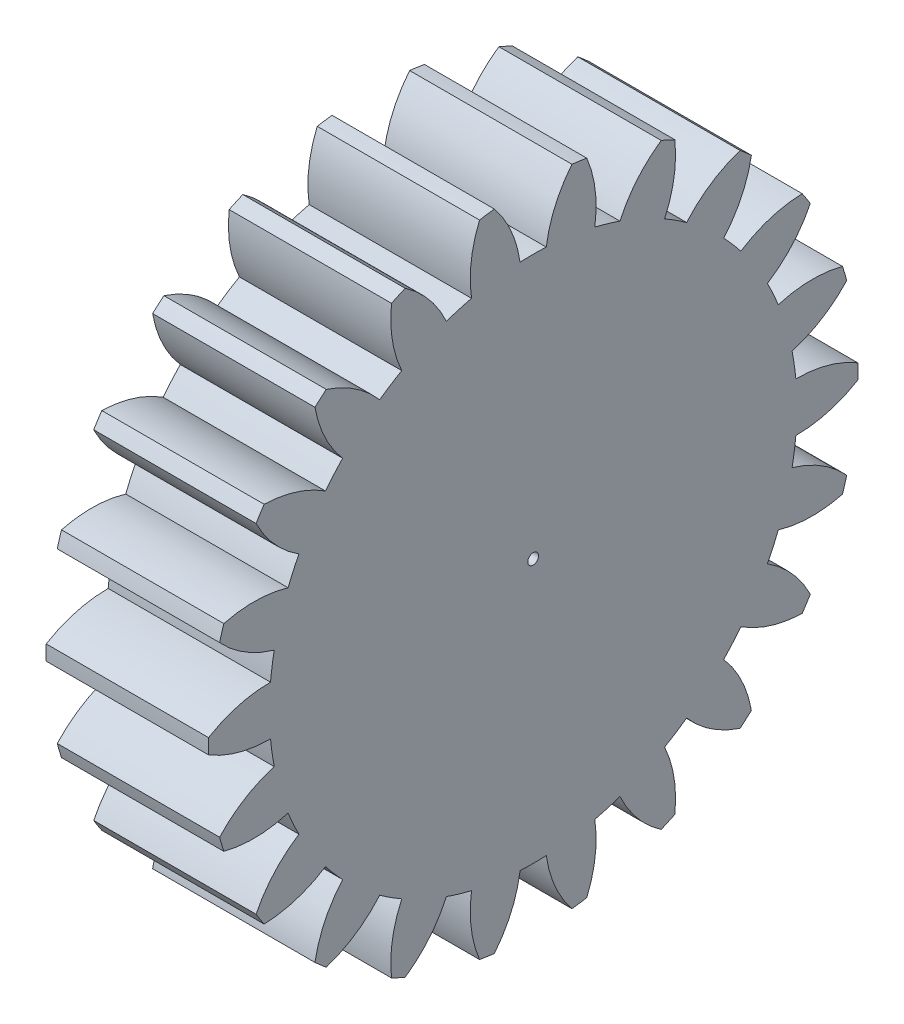
from build123d import *

# Parameters (mm, degrees)
BASPROSKE_W     = 12
BASPROSKE_H     = 24
TOOTHCUT_DEPTH  = 37
TEETHCUTS_COUNT = 22
TEETHCUTS_ANGLE = 343.636363636
BORSKE_R        = 0.4
BORE_DEPTH      = 50.0000508


with BuildPart() as part:
    # BasProSke → Base-Revolve (revolve)
    with BuildSketch(Plane(origin=(0, 0, 0), x_dir=(1, 0, 0), z_dir=(0, 1, 0)), mode=Mode.PRIVATE) as base_revolve_sk:
        with Locations((6, 12)):
            Rectangle(BASPROSKE_W, BASPROSKE_H)
    revolve(base_revolve_sk.sketch.rotate(Axis((-10, 0, 0), (1, 0, 0)), 180), axis=Axis((-10, 0, 0), (1, 0, 0)))

    # TooCutSke → ToothCut (cut, through all)
    with BuildSketch(Plane(origin=(0, 0, 0), x_dir=(0, 0, -1), z_dir=(1, 0, 0))):
        with BuildLine():
            ThreePointArc((0.968170358, 19.474949221), (0, 19.499), (-0.968170358, 19.474949221))
            ThreePointArc((-0.968170358, 19.474949221), (-1.624144469, 21.795843598), (-2.885568663, 23.851485041))
            ThreePointArc((-2.885568663, 23.851485041), (0, 24.0254), (2.885568663, 23.851485041))
            ThreePointArc((2.885568663, 23.851485041), (1.624144469, 21.795843598), (0.968170358, 19.474949221))
        make_face()
    toothcut = extrude(amount=TOOTHCUT_DEPTH, mode=Mode.SUBTRACT)

    # TeethCuts: ToothCut ×22 about axis
    teethcuts_axis = Axis((-10, 0, 0), (1, 0, 0))
    for i in range(1, TEETHCUTS_COUNT):
        add(toothcut.rotate(teethcuts_axis, i * TEETHCUTS_ANGLE / (TEETHCUTS_COUNT - 1)), mode=Mode.SUBTRACT)

    # BorSke → Bore (cut, symmetric)
    with BuildSketch(Plane(origin=(0, 0, 0), x_dir=(0, 0, -1), z_dir=(1, 0, 0))):
        with Locations(Location((0, 0, 0), (0, 0, 180))):
            Circle(BORSKE_R)
    extrude(amount=BORE_DEPTH, both=True, mode=Mode.SUBTRACT)


solid = part.part
